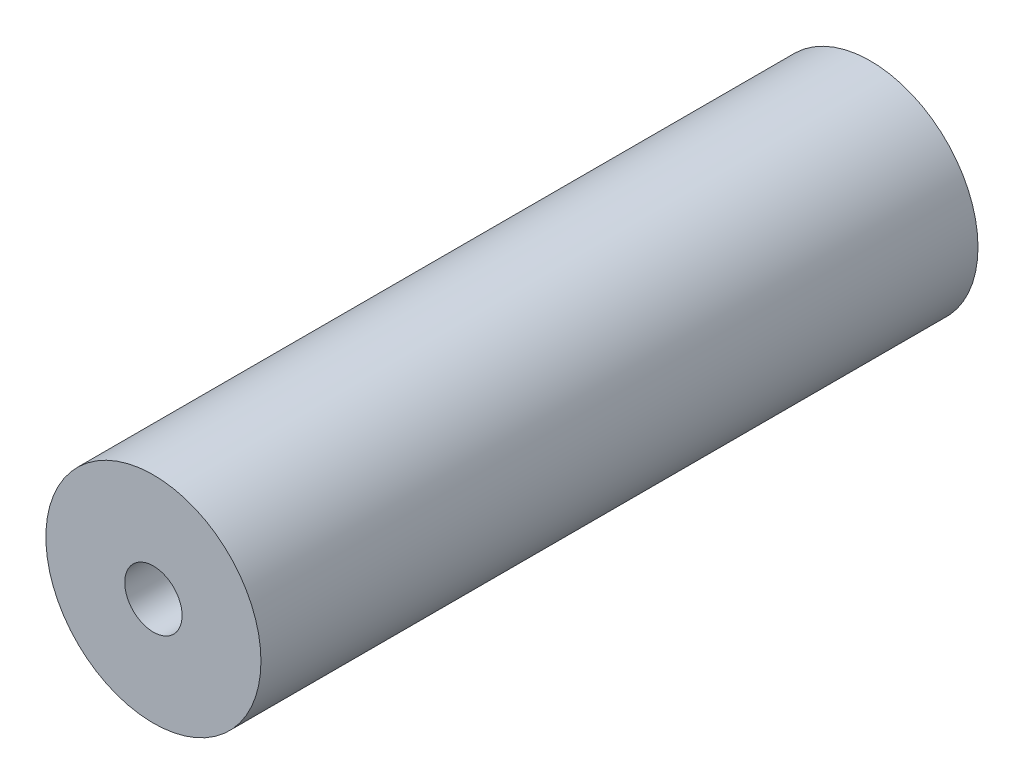
from build123d import *

# Parameters (mm, degrees)
SKETCH_1_R      = 1.5
SKETCH_1_R_2    = 0.4
EXTRUDE_1_DEPTH = 10


with BuildPart() as part:
    # Эскиз1 → Бобышка-Вытянуть1 (new body)
    with BuildSketch(Plane.XY):
        Circle(SKETCH_1_R)
        Circle(SKETCH_1_R_2, mode=Mode.SUBTRACT)
    extrude(amount=EXTRUDE_1_DEPTH)


solid = part.part
